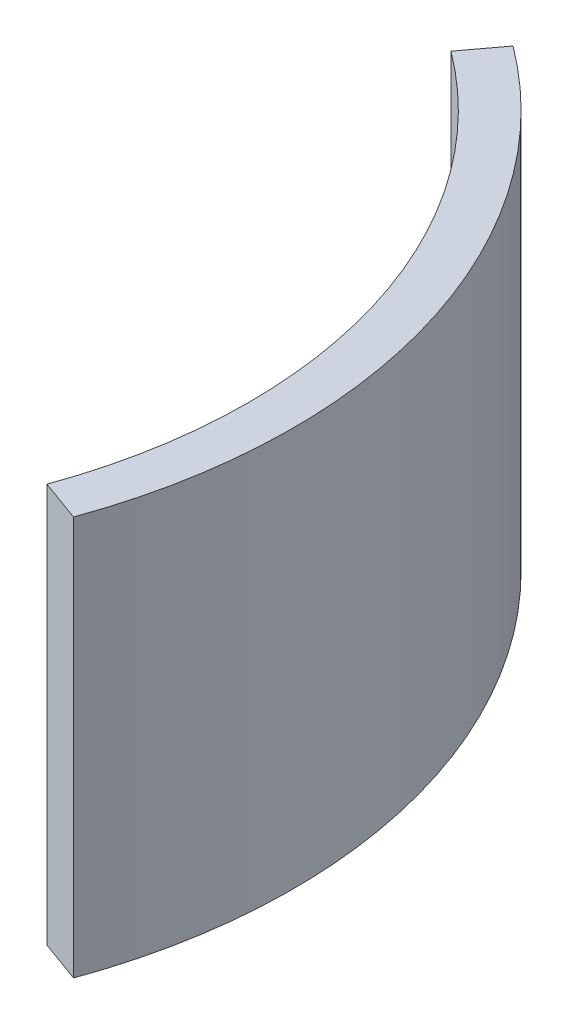
from build123d import *

# Parameters (mm, degrees)
BOSS_EXTRUDE1_DEPTH = 45


with BuildPart() as part:
    # Sketch1 → Boss-Extrude1 (new body)
    with BuildSketch(Plane(origin=(0, 0, 0), x_dir=(1, 0, 0), z_dir=(0, 1, 0))):
        with BuildLine():
            Line((53.607402933, -19.371276436), (58.309806699, -21.070511212))
            ThreePointArc((58.309806699, -21.070511212), (59.389034579, 17.802880997), (37.103445862, 49.672268975))
            Line((37.103445862, 49.672268975), (34.111232486, 45.666440832))
            ThreePointArc((34.111232486, 45.666440832), (54.599596306, 16.367164787), (53.607402933, -19.371276436))
        make_face()
    extrude(amount=BOSS_EXTRUDE1_DEPTH)


solid = part.part
